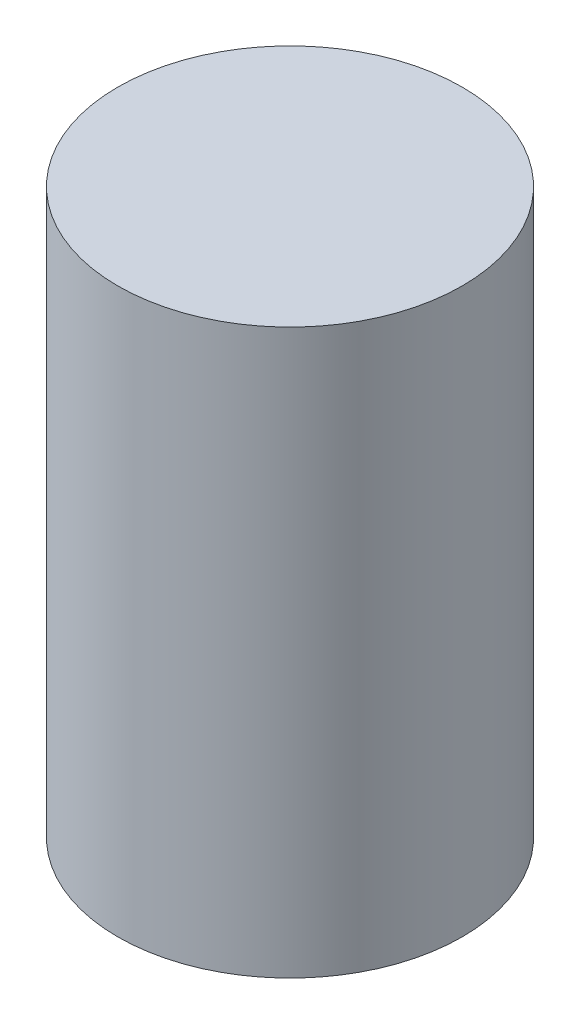
from build123d import *

# Parameters (mm, degrees)
SWEEP1_PROFILE_R = 4.699


with BuildPart() as part:
    # Sweep1: sweep along a curve in space
    with BuildLine() as sweep1_path:
        Line((266.6111, -155.9767, 163.3218), (266.6111, -140.5937, 163.3218))
    # Sweep1 profile (on start of the path) → Sweep1 (sweep)
    with BuildSketch(Plane(origin=(266.6111, -155.9767, 163.3218), x_dir=(0, 0, 1), z_dir=(0, 1, 0))):
        Circle(SWEEP1_PROFILE_R)
    sweep(path=sweep1_path.line)


solid = part.part
